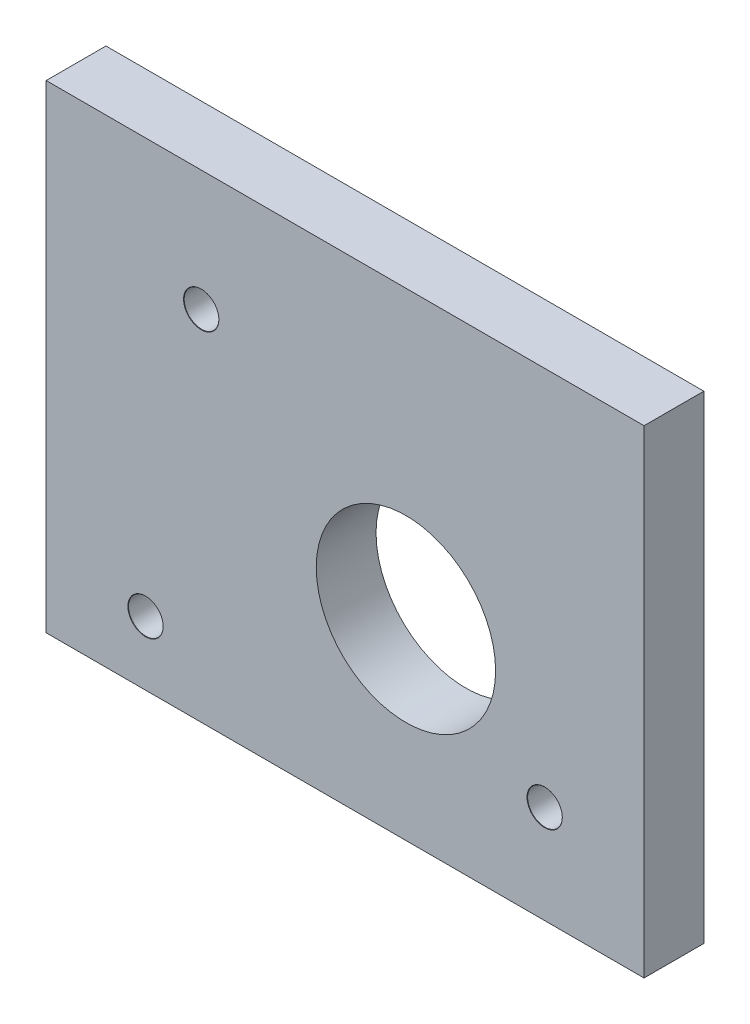
from build123d import *

# Parameters (mm, degrees)
SKETCH1_W                        = 50
SKETCH1_H                        = 40
BOSS_EXTRUDE1_DEPTH              = 2.5
M2_5_CLEARANCE_HOLE2_D           = 2.9
M2_5_CLEARANCE_HOLE2_CSINK_D     = 2.95
M2_5_CLEARANCE_HOLE2_CSINK_ANGLE = 90
SKETCH4_R                        = 7.5
CUT_EXTRUDE1_DEPTH               = 55.441590725


with BuildPart() as part:
    # Sketch1 → Boss-Extrude1 (new, symmetric)
    with BuildSketch(Plane.XY):
        with Locations((16.688846575, 14.654391813)):
            Rectangle(SKETCH1_W, SKETCH1_H)
    extrude(amount=BOSS_EXTRUDE1_DEPTH, both=True)

    # M2.5 Clearance Hole2 (through all)
    with Locations(Plane.XY.offset(2.5)):
        with Locations((4.655068225, 24.562783633), (33.37769315, 2.86), (0, 0)):
            CounterSinkHole(M2_5_CLEARANCE_HOLE2_D / 2, M2_5_CLEARANCE_HOLE2_CSINK_D / 2, counter_sink_angle=M2_5_CLEARANCE_HOLE2_CSINK_ANGLE)

    # Sketch4 → Cut-Extrude1 (cut, through all)
    with BuildSketch(Plane.XY.offset(2.5)):
        with Locations((21.775361697, 10.694915753)):
            Circle(SKETCH4_R)
    extrude(amount=-CUT_EXTRUDE1_DEPTH, mode=Mode.SUBTRACT)


solid = part.part
